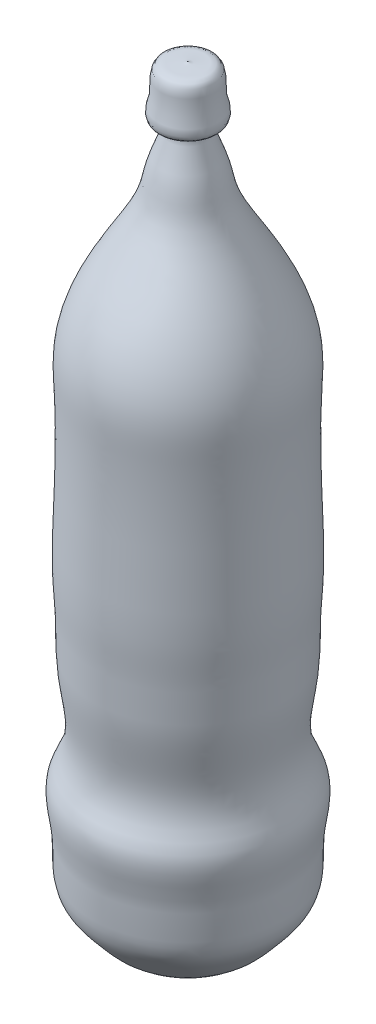
from build123d import *


with BuildPart() as part:
    # Croquis5 → Revolución3 (revolve)
    with BuildSketch(Plane(origin=(0, 0, 0), x_dir=(0, 0, -1), z_dir=(1, 0, 0))):
        with BuildLine():
            Line((397.480925737, 750.217626313), (397.480925737, 24.990424257))
            add(Edge.make_bspline(
                [(397.480925737, 24.990424257), (406.136257749, 15.178606098), (428.647560535, 15.799342956), (451.580732494, 21.603265696), (460.756257984, 28.651816292), (475.966768828, 46.938585833), (493.187134964, 67.139245365), (486.729493733, 108.00046593), (498.938451387, 144.934171777), (484.585989861, 169.58739142), (479.661628475, 191.906396845), (482.912597343, 219.060531324), (488.374789239, 251.156375952), (487.337175211, 285.292903216), (491.257105427, 331.302318402), (488.180779166, 394.907694942), (487.621951873, 459.130193297), (491.037757835, 517.560331416), (476.27568099, 561.476913793), (453.114960116, 600.428115784), (429.19679824, 639.706667841), (428.227882464, 666.009986634), (409.27697857, 705.424393558), (425.25205898, 701.013469699), (427.723381037, 711.396270377), (421.931417148, 722.621059578), (424.528358648, 735.784682706), (419.8327696, 753.561422645), (402.528848001, 747.210844751), (397.480925737, 750.217626313)],
                knots=[0, 0, 0, 0, 0.052717447, 0.061593325, 0.088758773, 0.102898764, 0.131342266, 0.186397137, 0.237248029, 0.26137887, 0.284282649, 0.317845459, 0.357762008, 0.400412161, 0.439042856, 0.522294801, 0.62685959, 0.668482467, 0.729840733, 0.786637081, 0.834770465, 0.880091716, 0.911823575, 0.917914728, 0.925646201, 0.941175654, 0.963532942, 0.972206747, 1, 1, 1, 1], degree=3))
        make_face()
    revolve(axis=Axis((0, 750.217626313, -397.480925737), (0, -1, 0)))


solid = part.part
